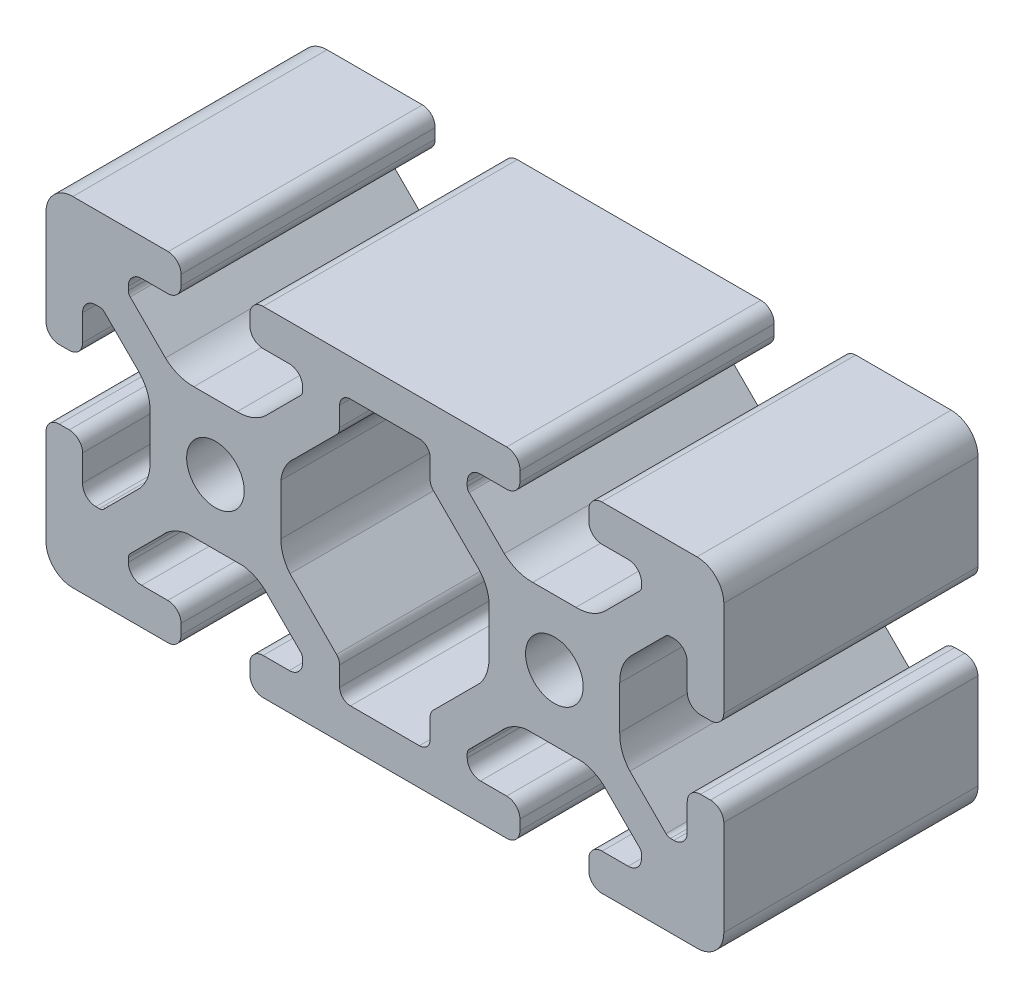
from build123d import *

# Parameters (mm, degrees)
SKETCH1_R      = 3.4
EXTRUDE1_DEPTH = 30


with BuildPart() as part:
    # Sketch1 → Extrude1 (new body)
    with BuildSketch(Plane.XY):
        with BuildLine():
            Line((-14.371895096, 20), (14.371895096, 20))
            ThreePointArc((14.371895096, 20), (15.50899084, 19.51254943), (15.94, 18.352883145))
            Line((15.94, 18.352883145), (15.94, 17.172883145))
            ThreePointArc((15.94, 17.172883145), (15.453758432, 16.112250378), (14.37, 15.68))
            Line((14.37, 15.68), (11.285, 15.68))
            ThreePointArc((11.285, 15.68), (10.174842354, 15.220157646), (9.715, 14.11))
            Line((9.715, 14.11), (9.715, 13.654503602))
            ThreePointArc((9.715, 13.654503602), (9.772851555, 13.363664194), (9.937598846, 13.117102448))
            Line((9.937598846, 13.117102448), (14.091872782, 8.962828513))
            ThreePointArc((14.091872782, 8.962828513), (15.647416634, 8.002049766), (17.450629992, 7.7))
            Line((17.450629992, 7.7), (22.549370008, 7.7))
            ThreePointArc((22.549370008, 7.7), (24.352583366, 8.002049766), (25.908127218, 8.962828513))
            Line((25.908127218, 8.962828513), (30.062401154, 13.117102448))
            ThreePointArc((30.062401154, 13.117102448), (30.227148445, 13.363664194), (30.285, 13.654503602))
            Line((30.285, 13.654503602), (30.285, 14.11))
            ThreePointArc((30.285, 14.11), (29.825157646, 15.220157646), (28.715, 15.68))
            Line((28.715, 15.68), (25.63, 15.68))
            ThreePointArc((25.63, 15.68), (24.519842354, 16.139842354), (24.06, 17.25))
            Line((24.06, 17.25), (24.06, 18.431164164))
            ThreePointArc((24.06, 18.431164164), (24.498672143, 19.519739968), (25.569550674, 20))
            Line((25.569550674, 20), (33, 20))
            Line((33, 20), (36.83, 20))
            ThreePointArc((36.83, 20), (39.067780363, 19.075288119), (40, 16.840624931))
            Line((40, 16.840624931), (40, 13.010624931))
            Line((40, 13.010624931), (40, 5.582508737))
            ThreePointArc((40, 5.582508737), (39.486387554, 4.464397964), (38.324306777, 4.06))
            Line((38.324306777, 4.06), (37.144306789, 4.06))
            ThreePointArc((37.144306789, 4.06), (36.103082753, 4.554299861), (35.68, 5.626438298))
            Line((35.68, 5.626438298), (35.68, 8.711438298))
            ThreePointArc((35.68, 8.711438298), (35.220157646, 9.821595945), (34.11, 10.281438298))
            Line((34.11, 10.281438298), (33.650941901, 10.281438298))
            ThreePointArc((33.650941901, 10.281438298), (33.360102492, 10.223586743), (33.113540747, 10.058839452))
            Line((33.113540747, 10.058839452), (29.01112516, 5.956423865))
            ThreePointArc((29.01112516, 5.956423865), (28.027864944, 4.392105869), (27.715866667, 2.570966522))
            Line((27.715866667, 2.570966522), (27.715866667, -2.502014759))
            ThreePointArc((27.715866667, -2.502014759), (27.988460835, -4.298258683), (28.915473265, -5.86077197))
            Line((28.915473265, -5.86077197), (33.171894658, -10.117193363))
            ThreePointArc((33.171894658, -10.117193363), (33.418456403, -10.281940654), (33.709295811, -10.339792209))
            Line((33.709295811, -10.339792209), (34.110956402, -10.339792209))
            ThreePointArc((34.110956402, -10.339792209), (35.240319888, -9.860405851), (35.68, -8.714999999))
            Line((35.68, -8.714999999), (35.68, -5.629999999))
            ThreePointArc((35.68, -5.629999999), (36.13984232, -4.519842386), (37.249999905, -4.06))
            Line((37.249999905, -4.06), (38.43, -4.06))
            ThreePointArc((38.43, -4.06), (39.519320595, -4.498268351), (40, -5.569550674))
            Line((40, -5.569550674), (40, -13))
            Line((40, -13), (40, -16.83))
            ThreePointArc((40, -16.83), (39.153330856, -18.99480488), (37.057427332, -20))
            Line((37.057427332, -20), (33.227427332, -20))
            Line((33.227427332, -20), (25.796978006, -20))
            ThreePointArc((25.796978006, -20), (24.580537154, -19.606606664), (24.06, -18.438904761))
            Line((24.06, -18.438904761), (24.06, -17.25))
            ThreePointArc((24.06, -17.25), (24.519842354, -16.139842354), (25.63, -15.68))
            Line((25.63, -15.68), (28.715, -15.68))
            ThreePointArc((28.715, -15.68), (29.825157646, -15.220157646), (30.285, -14.11))
            Line((30.285, -14.11), (30.285, -13.654503602))
            ThreePointArc((30.285, -13.654503602), (30.227148445, -13.363664194), (30.062401154, -13.117102448))
            Line((30.062401154, -13.117102448), (26.309520343, -9.364221638))
            ThreePointArc((26.309520343, -9.364221638), (24.979669869, -8.257223741), (23.341546451, -7.7))
            Line((23.341546451, -7.7), (16.658453549, -7.7))
            ThreePointArc((16.658453549, -7.7), (15.020330131, -8.257223741), (13.690479657, -9.364221638))
            Line((13.690479657, -9.364221638), (9.937598846, -13.117102448))
            ThreePointArc((9.937598846, -13.117102448), (9.772851555, -13.363664194), (9.715, -13.654503602))
            Line((9.715, -13.654503602), (9.715, -14.11))
            ThreePointArc((9.715, -14.11), (10.174842354, -15.220157646), (11.285, -15.68))
            Line((11.285, -15.68), (14.37, -15.68))
            ThreePointArc((14.37, -15.68), (15.480157646, -16.139842354), (15.94, -17.25))
            Line((15.94, -17.25), (15.94, -18.43))
            ThreePointArc((15.94, -18.43), (15.480157646, -19.540157646), (14.37, -20))
            Line((14.37, -20), (5.99100603, -20))
            Line((5.99100603, -20), (-1.780052417, -20))
            Line((-1.780052417, -20), (-5.99100603, -20))
            Line((-5.99100603, -20), (-14.37, -20))
            ThreePointArc((-14.37, -20), (-15.480157646, -19.540157646), (-15.94, -18.43))
            Line((-15.94, -18.43), (-15.94, -17.25))
            ThreePointArc((-15.94, -17.25), (-15.480157646, -16.139842354), (-14.37, -15.68))
            Line((-14.37, -15.68), (-11.285, -15.68))
            ThreePointArc((-11.285, -15.68), (-10.174842354, -15.220157646), (-9.715, -14.11))
            Line((-9.715, -14.11), (-9.715, -13.654503602))
            ThreePointArc((-9.715, -13.654503602), (-9.772851555, -13.363664194), (-9.937598846, -13.117102448))
            Line((-9.937598846, -13.117102448), (-13.690479657, -9.364221638))
            ThreePointArc((-13.690479657, -9.364221638), (-15.020330131, -8.257223741), (-16.658453549, -7.7))
            Line((-16.658453549, -7.7), (-23.341546451, -7.7))
            ThreePointArc((-23.341546451, -7.7), (-24.979669869, -8.257223741), (-26.309520343, -9.364221638))
            Line((-26.309520343, -9.364221638), (-30.062401154, -13.117102448))
            ThreePointArc((-30.062401154, -13.117102448), (-30.227148445, -13.363664194), (-30.285, -13.654503602))
            Line((-30.285, -13.654503602), (-30.285, -14.11))
            ThreePointArc((-30.285, -14.11), (-29.825157646, -15.220157646), (-28.715, -15.68))
            Line((-28.715, -15.68), (-25.63, -15.68))
            ThreePointArc((-25.63, -15.68), (-24.519842354, -16.139842354), (-24.06, -17.25))
            Line((-24.06, -17.25), (-24.06, -18.438904761))
            ThreePointArc((-24.06, -18.438904761), (-24.580537154, -19.606606664), (-25.796978006, -20))
            Line((-25.796978006, -20), (-33.227427332, -20))
            Line((-33.227427332, -20), (-37.057427332, -20))
            ThreePointArc((-37.057427332, -20), (-39.153330856, -18.99480488), (-40, -16.83))
            Line((-40, -16.83), (-40, -13))
            Line((-40, -13), (-40, -5.569550674))
            ThreePointArc((-40, -5.569550674), (-39.519320595, -4.498268351), (-38.43, -4.06))
            Line((-38.43, -4.06), (-37.249999905, -4.06))
            ThreePointArc((-37.249999905, -4.06), (-36.13984232, -4.519842386), (-35.68, -5.629999999))
            Line((-35.68, -5.629999999), (-35.68, -8.714999999))
            ThreePointArc((-35.68, -8.714999999), (-35.240319888, -9.860405851), (-34.110956402, -10.339792209))
            Line((-34.110956402, -10.339792209), (-33.709295811, -10.339792209))
            ThreePointArc((-33.709295811, -10.339792209), (-33.418456403, -10.281940654), (-33.171894658, -10.117193363))
            Line((-33.171894658, -10.117193363), (-28.915473265, -5.86077197))
            ThreePointArc((-28.915473265, -5.86077197), (-27.988460835, -4.298258683), (-27.715866667, -2.502014759))
            Line((-27.715866667, -2.502014759), (-27.715866667, 2.570966522))
            ThreePointArc((-27.715866667, 2.570966522), (-28.027864944, 4.392105869), (-29.01112516, 5.956423865))
            Line((-29.01112516, 5.956423865), (-33.113540747, 10.058839452))
            ThreePointArc((-33.113540747, 10.058839452), (-33.360102492, 10.223586743), (-33.650941901, 10.281438298))
            Line((-33.650941901, 10.281438298), (-34.11, 10.281438298))
            ThreePointArc((-34.11, 10.281438298), (-35.220157646, 9.821595945), (-35.68, 8.711438298))
            Line((-35.68, 8.711438298), (-35.68, 5.626438298))
            ThreePointArc((-35.68, 5.626438298), (-36.103082753, 4.554299861), (-37.144306789, 4.06))
            Line((-37.144306789, 4.06), (-38.324306777, 4.06))
            ThreePointArc((-38.324306777, 4.06), (-39.486387554, 4.464397964), (-40, 5.582508737))
            Line((-40, 5.582508737), (-40, 13.010624931))
            Line((-40, 13.010624931), (-40, 16.840624931))
            ThreePointArc((-40, 16.840624931), (-39.067780363, 19.075288119), (-36.83, 20))
            Line((-36.83, 20), (-33, 20))
            Line((-33, 20), (-25.569550674, 20))
            ThreePointArc((-25.569550674, 20), (-24.498672143, 19.519739968), (-24.06, 18.431164164))
            Line((-24.06, 18.431164164), (-24.06, 17.25))
            ThreePointArc((-24.06, 17.25), (-24.519842354, 16.139842354), (-25.63, 15.68))
            Line((-25.63, 15.68), (-28.715, 15.68))
            ThreePointArc((-28.715, 15.68), (-29.825157646, 15.220157646), (-30.285, 14.11))
            Line((-30.285, 14.11), (-30.285, 13.654503602))
            ThreePointArc((-30.285, 13.654503602), (-30.227148445, 13.363664194), (-30.062401154, 13.117102448))
            Line((-30.062401154, 13.117102448), (-25.908127218, 8.962828513))
            ThreePointArc((-25.908127218, 8.962828513), (-24.352583366, 8.002049766), (-22.549370008, 7.7))
            Line((-22.549370008, 7.7), (-17.450629992, 7.7))
            ThreePointArc((-17.450629992, 7.7), (-15.647416634, 8.002049766), (-14.091872782, 8.962828513))
            Line((-14.091872782, 8.962828513), (-9.937598846, 13.117102448))
            ThreePointArc((-9.937598846, 13.117102448), (-9.772851555, 13.363664194), (-9.715, 13.654503602))
            Line((-9.715, 13.654503602), (-9.715, 14.11))
            ThreePointArc((-9.715, 14.11), (-10.174842354, 15.220157646), (-11.285, 15.68))
            Line((-11.285, 15.68), (-14.37, 15.68))
            ThreePointArc((-14.37, 15.68), (-15.453758432, 16.112250378), (-15.94, 17.172883145))
            Line((-15.94, 17.172883145), (-15.94, 18.352883145))
            ThreePointArc((-15.94, 18.352883145), (-15.50899084, 19.51254943), (-14.371895096, 20))
        make_face()
        with Locations((-20, 0)):
            Circle(SKETCH1_R, mode=Mode.SUBTRACT)
        with Locations((20, 0)):
            Circle(SKETCH1_R, mode=Mode.SUBTRACT)
        with BuildLine():
            Line((4.071751167, 15.68), (-4.071751167, 15.68))
            ThreePointArc((-4.071751167, 15.68), (-4.969776779, 15.308025612), (-5.341751167, 14.41))
            Line((-5.341751167, 14.41), (-5.341751167, 12.129598762))
            ThreePointArc((-5.341751167, 12.129598762), (-5.438424161, 11.643590803), (-5.713725555, 11.23157315))
            Line((-5.713725555, 11.23157315), (-10.598777023, 6.346521682))
            ThreePointArc((-10.598777023, 6.346521682), (-11.737774423, 4.964558417), (-12.284133333, 3.259087959))
            Line((-12.284133333, 3.259087959), (-12.284133333, -2.724972544))
            ThreePointArc((-12.284133333, -2.724972544), (-12.005210609, -4.328708179), (-11.201199443, -5.744099262))
            Line((-11.201199443, -5.744099262), (-5.713725555, -11.23157315))
            ThreePointArc((-5.713725555, -11.23157315), (-5.438424161, -11.643590803), (-5.341751167, -12.129598762))
            Line((-5.341751167, -12.129598762), (-5.341751167, -14.41))
            ThreePointArc((-5.341751167, -14.41), (-4.969776779, -15.308025612), (-4.071751167, -15.68))
            Line((-4.071751167, -15.68), (4.071751167, -15.68))
            ThreePointArc((4.071751167, -15.68), (4.969776779, -15.308025612), (5.341751167, -14.41))
            Line((5.341751167, -14.41), (5.341751167, -12.129598762))
            ThreePointArc((5.341751167, -12.129598762), (5.438424161, -11.643590803), (5.713725555, -11.23157315))
            Line((5.713725555, -11.23157315), (11.201199443, -5.744099262))
            ThreePointArc((11.201199443, -5.744099262), (12.005210609, -4.328708179), (12.284133333, -2.724972544))
            Line((12.284133333, -2.724972544), (12.284133333, 3.259087959))
            ThreePointArc((12.284133333, 3.259087959), (11.737774423, 4.964558417), (10.598777023, 6.346521682))
            Line((10.598777023, 6.346521682), (5.713725555, 11.23157315))
            ThreePointArc((5.713725555, 11.23157315), (5.438424161, 11.643590803), (5.341751167, 12.129598762))
            Line((5.341751167, 12.129598762), (5.341751167, 14.41))
            ThreePointArc((5.341751167, 14.41), (4.969776779, 15.308025612), (4.071751167, 15.68))
        make_face(mode=Mode.SUBTRACT)
    extrude(amount=-EXTRUDE1_DEPTH)


solid = part.part
